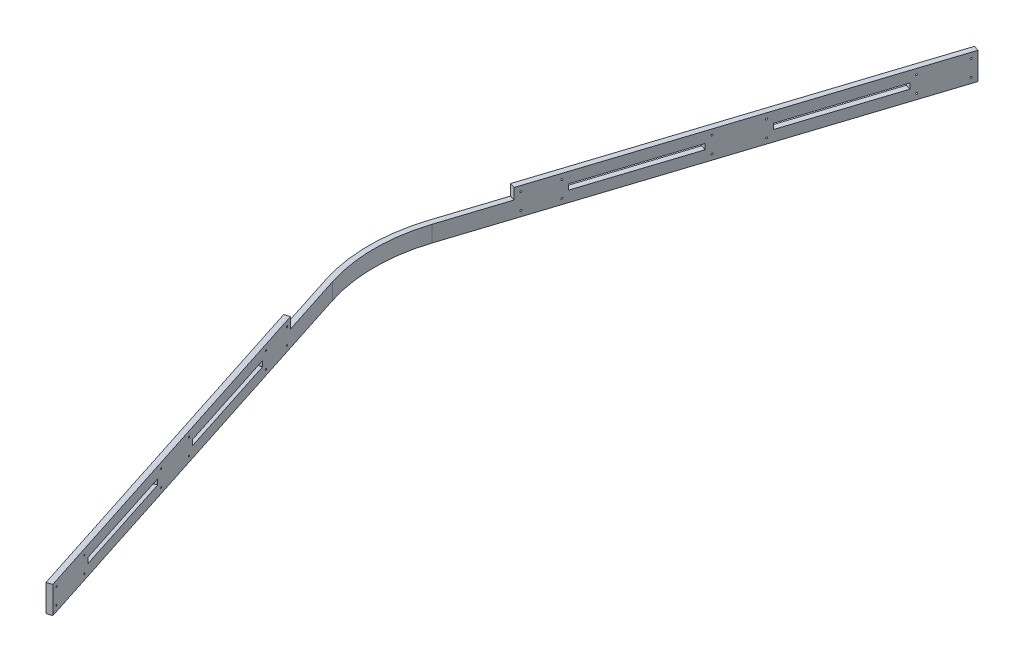
from build123d import *

# Parameters (mm, degrees)
BOSS_EXTRUDE1_DEPTH   = 5
BOSS_EXTRUDE1_2_DEPTH = 5
BOSS_EXTRUDE1_3_DEPTH = 5
BOSS_EXTRUDE1_4_DEPTH = 5
BOSS_EXTRUDE1_5_DEPTH = 5
BOSS_EXTRUDE2_DEPTH   = 20
BOSS_EXTRUDE3_DEPTH   = 20
SKETCH8_R             = 1.5
CUT_EXTRUDE2_DEPTH    = 535.790809635


with BuildPart() as part:
    # Sketch3 → Boss-Extrude1 (new body, symmetric)
    with BuildSketch(Plane(origin=(0, 0, 0), x_dir=(1, 0, 0), z_dir=(0, 1, 0))):
        Polygon((-49.523523643, -856.532206403), (-40.006093165, -853.463246139), (-70.69569581, -758.288941363), (-80.213126288, -761.357901628), align=None)
    extrude(amount=BOSS_EXTRUDE1_DEPTH, both=True)



with BuildPart() as body_2:
    # Sketch3 → Boss-Extrude1 2 (new body, symmetric)
    with BuildSketch(Plane(origin=(0, 0, 0), x_dir=(1, 0, 0), z_dir=(0, 1, 0))):
        with BuildLine():
            Line((-233.661139514, -285.486377751), (-295.040344804, -95.1377682))
            ThreePointArc((-295.040344804, -95.1377682), (-310, 0), (-295.040344804, 95.1377682))
            Line((-295.040344804, 95.1377682), (-233.661139514, 285.486377751))
            Line((-233.661139514, 285.486377751), (-224.143709036, 282.417417486))
            Line((-224.143709036, 282.417417486), (-285.522914326, 92.068807935))
            ThreePointArc((-285.522914326, 92.068807935), (-300, 0), (-285.522914326, -92.068807935))
            Line((-285.522914326, -92.068807935), (-224.143709036, -282.417417486))
            Line((-224.143709036, -282.417417486), (-233.661139514, -285.486377751))
        make_face()
    extrude(amount=BOSS_EXTRUDE1_2_DEPTH, both=True)


with BuildPart() as body_3:
    # Sketch3 → Boss-Extrude1 3 (new body, symmetric)
    with BuildSketch(Plane(origin=(0, 0, 0), x_dir=(1, 0, 0), z_dir=(0, 1, 0))):
        Polygon((-132.074901101, -567.940331812), (-141.592331578, -571.009292077), (-172.281934223, -475.834987302), (-162.764503746, -472.766027037), align=None)
    extrude(amount=BOSS_EXTRUDE1_3_DEPTH, both=True)


with BuildPart() as body_4:
    # Sketch3 → Boss-Extrude1 4 (new body, symmetric)
    with BuildSketch(Plane(origin=(0, 0, 0), x_dir=(1, 0, 0), z_dir=(0, 1, 0))):
        Polygon((-70.69569581, 758.288941363), (-40.006093165, 853.463246139), (-49.523523643, 856.532206403), (-80.213126288, 761.357901628), align=None)
    extrude(amount=BOSS_EXTRUDE1_4_DEPTH, both=True)


with BuildPart() as body_5:
    # Sketch3 → Boss-Extrude1 5 (new body, symmetric)
    with BuildSketch(Plane(origin=(0, 0, 0), x_dir=(1, 0, 0), z_dir=(0, 1, 0))):
        Polygon((-162.764503746, 472.766027037), (-132.074901101, 567.940331812), (-141.592331578, 571.009292077), (-172.281934223, 475.834987302), align=None)
    extrude(amount=BOSS_EXTRUDE1_5_DEPTH, both=True)


with BuildPart() as part_1:
    add(part.part)

    add(body_2.part)  # Boss-Extrude2 merges body 2

    add(body_3.part)  # Boss-Extrude2 merges body 3

    add(body_4.part)  # Boss-Extrude2 merges body 4

    add(body_5.part)  # Boss-Extrude2 merges body 5
    # Sketch4 → Boss-Extrude2 (add)
    with BuildSketch(Plane(origin=(0, 5, 0), x_dir=(1, 0, 0), z_dir=(0, 1, 0))):
        Polygon((-49.523523643, -856.532206403), (-258.21282163, -209.34693393), (-248.695391152, -206.277973666), (-40.006093165, -853.463246139), align=None)
        Polygon((-49.523523643, 856.532206403), (-40.006093165, 853.463246139), (-248.695391152, 206.277973666), (-258.21282163, 209.34693393), align=None)
    extrude(amount=BOSS_EXTRUDE2_DEPTH)

    # Sketch5 → Boss-Extrude3 (add)
    with BuildSketch(Plane.XZ.offset(5)):
        with BuildLine():
            Line((-49.523523643, 856.532206403), (-40.006093165, 853.463246139))
            Line((-40.006093165, 853.463246139), (-285.522914326, 92.068807935))
            ThreePointArc((-285.522914326, 92.068807935), (-300, 0), (-285.522914326, -92.068807935))
            Line((-285.522914326, -92.068807935), (-40.006093165, -853.463246139))
            Line((-40.006093165, -853.463246139), (-49.523523643, -856.532206403))
            Line((-49.523523643, -856.532206403), (-295.040344804, -95.1377682))
            ThreePointArc((-295.040344804, -95.1377682), (-310, 0), (-295.040344804, 95.1377682))
            Line((-295.040344804, 95.1377682), (-49.523523643, 856.532206403))
        make_face()
    extrude(amount=BOSS_EXTRUDE3_DEPTH)

    # Sketch8 → Cut-Extrude2 (cut, through all)
    with BuildSketch(Plane(origin=(-295.040344804, 0, 95.1377682), x_dir=(0.306896026, 0, 0.951743048), z_dir=(-0.951743048, 0, 0.306896026))):
        with Locations((790, 15)):
            Circle(SKETCH8_R)
        with Locations((710, 15)):
            Circle(SKETCH8_R)
        with Locations((410, 15)):
            Circle(SKETCH8_R)
        with Locations((490, 15)):
            Circle(SKETCH8_R)
        with Locations((130, 15)):
            Circle(SKETCH8_R)
        with Locations((190, 15)):
            Circle(SKETCH8_R)
        with Locations((790, -15)):
            Circle(SKETCH8_R)
        with Locations((190, -15)):
            Circle(SKETCH8_R)
        with Locations((130, -15)):
            Circle(SKETCH8_R)
        with Locations((490, -15)):
            Circle(SKETCH8_R)
        with Locations((410, -15)):
            Circle(SKETCH8_R)
        with Locations((710, -15)):
            Circle(SKETCH8_R)
    cut_extrude2 = extrude(amount=-CUT_EXTRUDE2_DEPTH, mode=Mode.SUBTRACT)

    # Mirror1: Cut-Extrude2 across plane
    add(cut_extrude2.mirror(Plane.XY), mode=Mode.SUBTRACT)


solid = part_1.part
